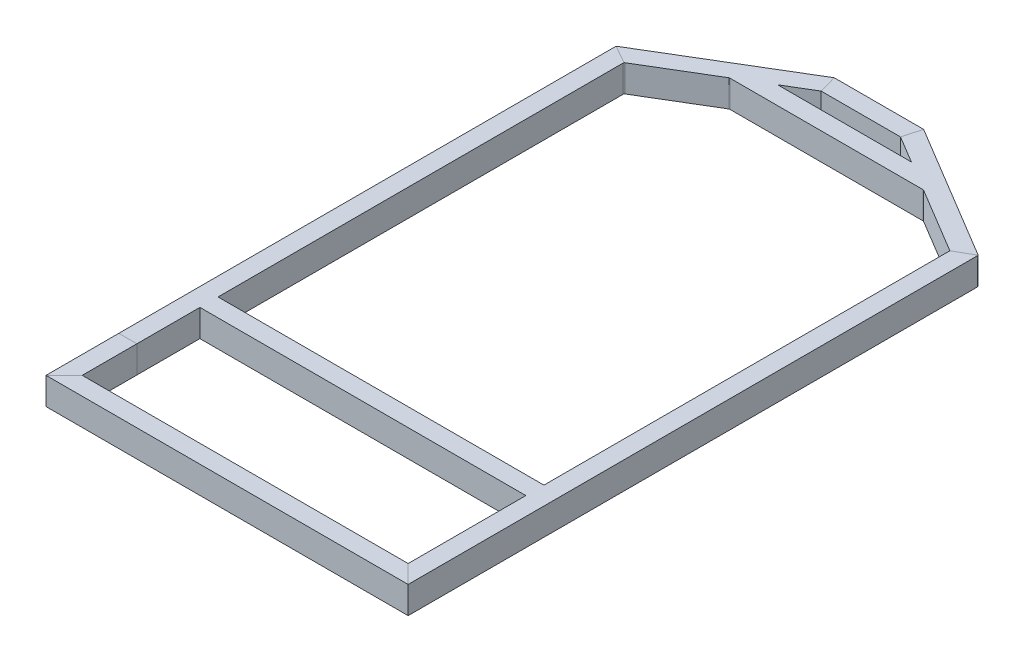
from build123d import *

# Parameters (mm, degrees)
SKETCH2_W               = 50.8
SKETCH2_H               = 75.9206
SKETCH2_W_2             = 44.8564
SKETCH2_H_2             = 69.977
CUT_EXTRUDE1_DEPTH      = 25.4
CUT_EXTRUDE2_DEPTH      = 25.4
BOSS_EXTRUDE1_REACH     = 967.2
SKETCH7_W               = 50.8
SKETCH7_H               = 75.9206
CUT_EXTRUDE3_DEPTH      = 25.4
SKETCH11_W              = 44.8564
SKETCH11_H              = 69.977
CUT_EXTRUDE4_DEPTH      = 482.6
CUT_EXTRUDE4_DEPTH_BACK = 482.6
BOSS_EXTRUDE2_DEPTH     = 75.9206
SKETCH13_W              = 44.8564
SKETCH13_H              = 69.977
CUT_EXTRUDE5_DEPTH      = 279.4
CUT_EXTRUDE5_DEPTH_BACK = 279.4
CUT_EXTRUDE6_DEPTH      = 25.4
FILLET2_R               = 4.191
FILLET3_R               = 4.191


with BuildPart() as part:
    # Sweep1: sweep along a path in Sketch3
    with BuildLine(Plane(origin=(0, 0, 0), x_dir=(1, 0, 0), z_dir=(0, 1, 0))) as sweep1_path:
        Line((0, -204.200684232), (0, 1395.206939042))
        Line((0, 1395.206939042), (382.5875, 1624.599315768))
        Line((382.5875, 1624.599315768), (633.4125, 1624.599315768))
        Line((633.4125, 1624.599315768), (1016, 1395.206939042))
        Line((1016, 1395.206939042), (1016, -204.200684232))
        Line((1016, -204.200684232), (0, -204.200684232))
    # Sketch2 → Sweep1 (sweep)
    with BuildSketch(Plane.XY):
        with Locations((25.4, 37.9603)):
            Rectangle(SKETCH2_W, SKETCH2_H)
        with Locations((25.4, 37.9603)):
            Rectangle(SKETCH2_W_2, SKETCH2_H_2, mode=Mode.SUBTRACT)
    sweep(path=sweep1_path.line, transition=Transition.RIGHT)

    # Sketch4 → Cut-Extrude1 (cut)
    with BuildSketch(Plane.XZ):
        with BuildLine():
            Line((469.9508, 188.312984232), (546.0492, 188.312984232))
            ThreePointArc((546.0492, 188.312984232), (555.5615, 178.800684232), (546.0492, 169.288384232))
            Line((546.0492, 169.288384232), (469.9508, 169.288384232))
            ThreePointArc((469.9508, 169.288384232), (460.4385, 178.800684232), (469.9508, 188.312984232))
        make_face()
    extrude(amount=-CUT_EXTRUDE1_DEPTH, mode=Mode.SUBTRACT)

    # Sketch5 → Cut-Extrude2 (cut)
    with BuildSketch(Plane.XZ):
        with BuildLine():
            Line((469.9, -1589.687015768), (546.1, -1589.687015768))
            ThreePointArc((546.1, -1589.687015768), (555.6123, -1599.199315768), (546.1, -1608.711615768))
            Line((546.1, -1608.711615768), (469.9, -1608.711615768))
            ThreePointArc((469.9, -1608.711615768), (460.3877, -1599.199315768), (469.9, -1589.687015768))
        make_face()
    extrude(amount=-CUT_EXTRUDE2_DEPTH, mode=Mode.SUBTRACT)

    # Sketch7 → Boss-Extrude1 (add, up to next)
    with BuildSketch(Plane.ZY.offset(-965.2), mode=Mode.PRIVATE) as boss_extrude1_sk1:
        with Locations((-202.199315768, 37.9603)):
            Rectangle(SKETCH7_W, SKETCH7_H)
    boss_extrude1_tool1 = extrude(boss_extrude1_sk1.sketch, amount=BOSS_EXTRUDE1_REACH, mode=Mode.PRIVATE) - part.part
    add(boss_extrude1_tool1.solids().sort_by_distance((965.2, 37.9603, -202.199316))[0])

    # Sketch8 → Cut-Extrude3 (cut)
    with BuildSketch(Plane.XZ):
        with BuildLine():
            Line((469.9508, -192.687015768), (546.0492, -192.687015768))
            ThreePointArc((546.0492, -192.687015768), (555.5615, -202.199315768), (546.0492, -211.711615768))
            Line((546.0492, -211.711615768), (469.9508, -211.711615768))
            ThreePointArc((469.9508, -211.711615768), (460.4385, -202.199315768), (469.9508, -192.687015768))
        make_face()
    extrude(amount=-CUT_EXTRUDE3_DEPTH, mode=Mode.SUBTRACT)

    # Sketch11 → Cut-Extrude4 (cut, two sides)
    with BuildSketch(Plane(origin=(508, 0, 0), x_dir=(0, 0, -1), z_dir=(1, 0, 0))) as cut_extrude4_sk:
        with Locations((202.199315768, 37.9603)):
            Rectangle(SKETCH11_W, SKETCH11_H)
    extrude(amount=CUT_EXTRUDE4_DEPTH, mode=Mode.SUBTRACT)
    extrude(cut_extrude4_sk.sketch, amount=-CUT_EXTRUDE4_DEPTH_BACK, mode=Mode.SUBTRACT)

    # Sketch12 → Boss-Extrude2 (add)
    with BuildSketch(Plane(origin=(0, 0, 0), x_dir=(1, 0, 0), z_dir=(0, 1, 0))):
        Polygon((320.396677865, 1528.079315768), (695.603322135, 1528.079315768), (780.329088864, 1477.279315768), (235.670911136, 1477.279315768), align=None)
    extrude(amount=BOSS_EXTRUDE2_DEPTH)

    # Sketch13 → Cut-Extrude5 (cut, two sides)
    with BuildSketch(Plane(origin=(508, 0, 0), x_dir=(0, 0, -1), z_dir=(1, 0, 0))) as cut_extrude5_sk:
        with Locations((1502.679315768, 37.9603)):
            Rectangle(SKETCH13_W, SKETCH13_H)
    extrude(amount=CUT_EXTRUDE5_DEPTH, mode=Mode.SUBTRACT)
    extrude(cut_extrude5_sk.sketch, amount=-CUT_EXTRUDE5_DEPTH_BACK, mode=Mode.SUBTRACT)

    # Sketch14 → Cut-Extrude6 (cut)
    with BuildSketch(Plane.XZ):
        with BuildLine():
            Line((469.9508, -1493.167015768), (546.0492, -1493.167015768))
            ThreePointArc((546.0492, -1493.167015768), (555.5615, -1502.679315768), (546.0492, -1512.191615768))
            Line((546.0492, -1512.191615768), (469.9508, -1512.191615768))
            ThreePointArc((469.9508, -1512.191615768), (460.4385, -1502.679315768), (469.9508, -1493.167015768))
        make_face()
    extrude(amount=-CUT_EXTRUDE6_DEPTH, mode=Mode.SUBTRACT)

    # Fillet2
    fillet2_edges = [part.edges().sort_by_distance(p)[0] for p in [
        (1016, 37.9603, -1395.206939042),
        (0, 37.9603, -1395.206939042),
        (633.4125, 37.9603, -1624.599315768),
        (382.5875, 37.9603, -1624.599315768),
    ]]
    fillet(fillet2_edges, radius=FILLET2_R)

    # Fillet3
    fillet3_edges = [part.edges().sort_by_distance(p)[0] for p in [
        (235.670911136, 37.9603, -1477.279315768),
        (780.329088864, 37.9603, -1477.279315768),
        (50.8, 37.9603, -1366.434142591),
        (968.1718, 37.9603, -1368.117351183),
    ]]
    fillet(fillet3_edges, radius=FILLET3_R)


solid = part.part
